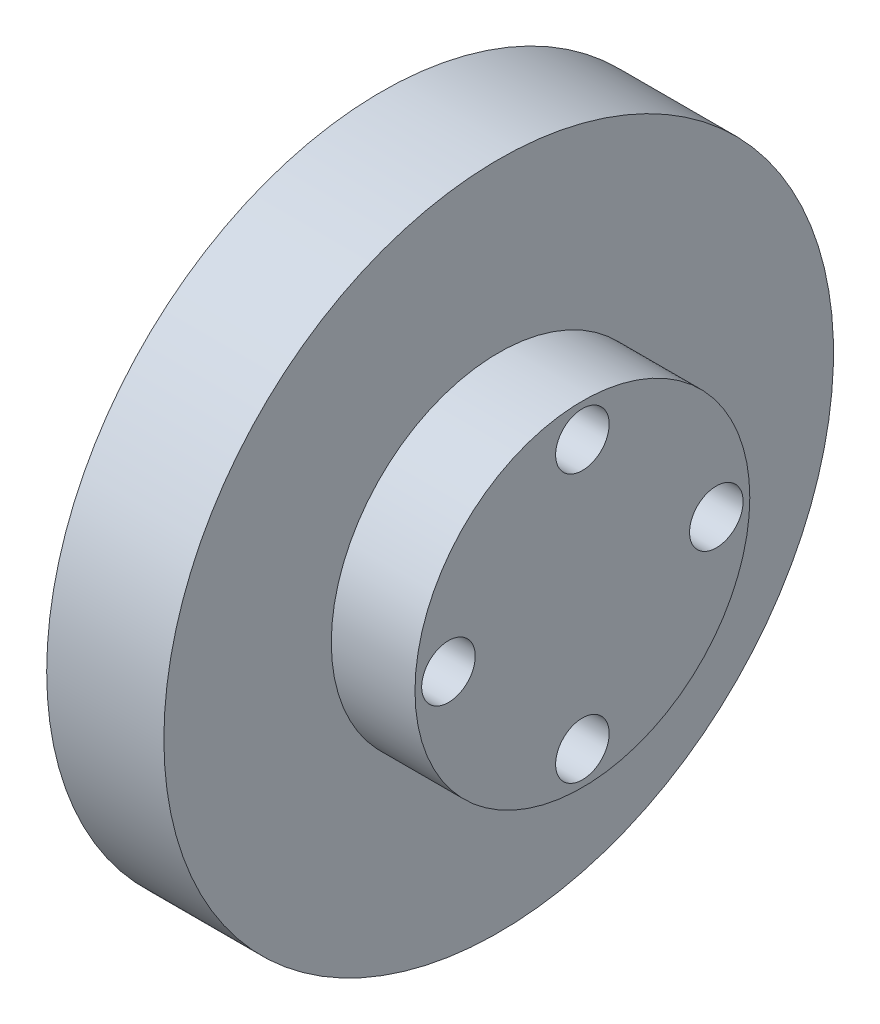
from build123d import *

# Parameters (mm, degrees)
CUT_EXTRUDE_1_DEPTH      = 10
CUT_EXTRUDE_1_DEPTH_BACK = 10
SKETCH_3_W               = 10
SKETCH_3_H               = 4.3
SKETCH_4_R               = 1.6
CUT_EXTRUDE_2_DEPTH      = 23


with BuildPart() as part:
    # 草图1 → 旋转1 (revolve)
    with BuildSketch(Plane.XY):
        Polygon((0, 0), (0, 2), (10, 2), (10, 20), (17, 20), (17, 10), (22, 10), (22, 0), align=None)
    revolve(axis=Axis((0, 0, 0), (1, 0, 0)))

    # 草图3 → 切除-拉伸1 (cut, two sides: drawn at the far end of the back side and taken through both)
    with BuildSketch(Plane.XY.offset(-CUT_EXTRUDE_1_DEPTH_BACK)):
        with Locations((5, 0.15)):
            Rectangle(SKETCH_3_W, SKETCH_3_H)
    extrude(amount=CUT_EXTRUDE_1_DEPTH + CUT_EXTRUDE_1_DEPTH_BACK, mode=Mode.SUBTRACT)

    # 草图4 → 切除-拉伸2 (cut)
    with BuildSketch(Plane(origin=(22, 0, 0), x_dir=(0, 0, -1), z_dir=(1, 0, 0))):
        with Locations((0, 8)):
            Circle(SKETCH_4_R)
        with Locations((8, 0)):
            Circle(SKETCH_4_R)
        with Locations((0, -8)):
            Circle(SKETCH_4_R)
        with Locations((-8, 0)):
            Circle(SKETCH_4_R)
    extrude(amount=-CUT_EXTRUDE_2_DEPTH, mode=Mode.SUBTRACT)


solid = part.part
